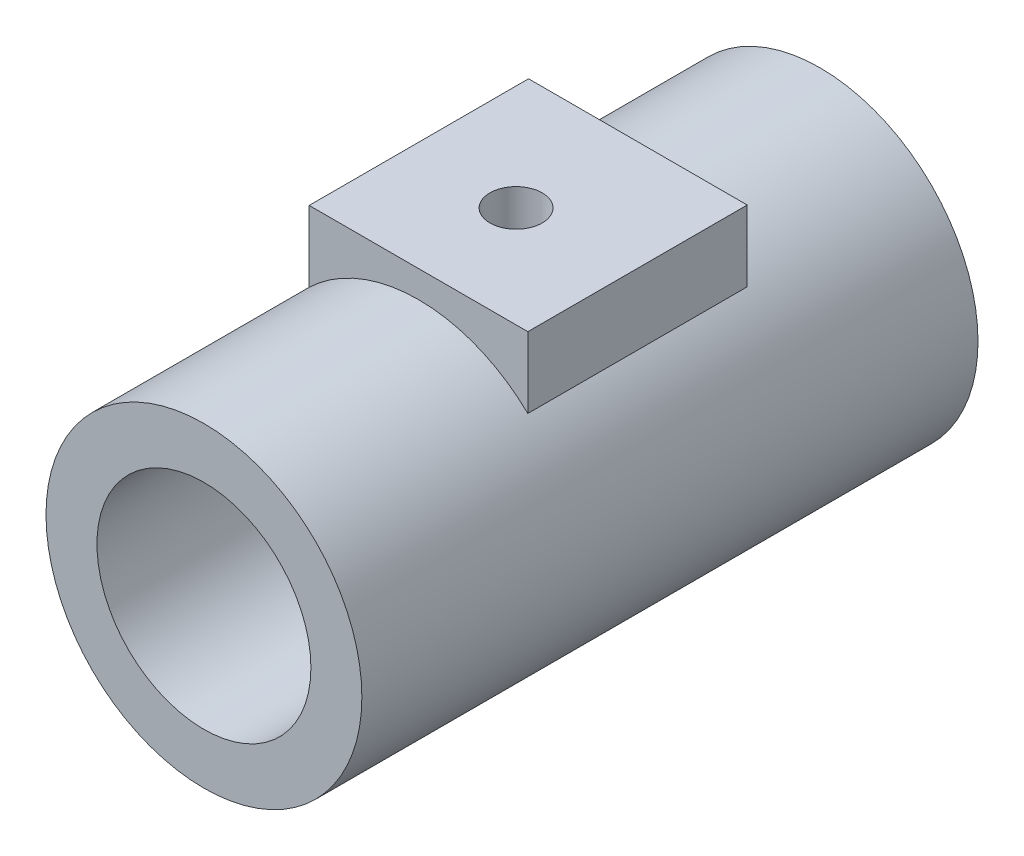
from build123d import *

# Parameters (mm, degrees)
SKETCH16_R               = 38.448520448
BOSS_EXTRUDE3_DEPTH      = 150
SKETCH17_R               = 26.04625397
CUT_EXTRUDE2_DEPTH       = 1
CUT_EXTRUDE2_DEPTH_BACK  = 151
SKETCH18_R               = 18.685585603
CUT_EXTRUDE3_DEPTH       = 39.448520448
CUT_EXTRUDE3_DEPTH_BACK  = 1
SKETCH19_W               = 53.228745634
SKETCH19_H               = 53.407658992
BOSS_EXTRUDE4_DEPTH      = 45
BOSS_EXTRUDE4_DEPTH_BACK = 1
SKETCH20_R               = 22.488274744
CUT_EXTRUDE4_DEPTH       = 46
CUT_EXTRUDE4_DEPTH_BACK  = 1
SKETCH21_W               = 53.228745634
SKETCH21_H               = 53.043515862
BOSS_EXTRUDE5_DEPTH      = 45
SKETCH22_R               = 6.364118175
CUT_EXTRUDE5_DEPTH       = 55
CUT_EXTRUDE5_DEPTH_BACK  = 1


with BuildPart() as part:
    # Sketch16 → Boss-Extrude3 (new body)
    with BuildSketch(Plane.XY):
        Circle(SKETCH16_R)
    extrude(amount=BOSS_EXTRUDE3_DEPTH)

    # Sketch17 → Cut-Extrude2 (cut, two sides)
    with BuildSketch(Plane.XY.offset(150)) as cut_extrude2_sk:
        Circle(SKETCH17_R)
    extrude(amount=CUT_EXTRUDE2_DEPTH, mode=Mode.SUBTRACT)
    extrude(cut_extrude2_sk.sketch, amount=-CUT_EXTRUDE2_DEPTH_BACK, mode=Mode.SUBTRACT)

    # Sketch18 → Cut-Extrude3 (cut, two sides)
    with BuildSketch(Plane(origin=(0, 0, 0), x_dir=(1, 0, 0), z_dir=(0, 1, 0))) as cut_extrude3_sk:
        with Locations((0, -71.055116097)):
            Circle(SKETCH18_R)
    extrude(amount=CUT_EXTRUDE3_DEPTH, mode=Mode.SUBTRACT)
    extrude(cut_extrude3_sk.sketch, amount=-CUT_EXTRUDE3_DEPTH_BACK, mode=Mode.SUBTRACT)

    # Sketch19 → Boss-Extrude4 (add, two sides)
    with BuildSketch(Plane(origin=(0, 0, 0), x_dir=(1, 0, 0), z_dir=(0, 1, 0))) as boss_extrude4_sk:
        with Locations((0, -71.055116097)):
            Rectangle(SKETCH19_W, SKETCH19_H)
    extrude(amount=BOSS_EXTRUDE4_DEPTH)
    extrude(boss_extrude4_sk.sketch, amount=-BOSS_EXTRUDE4_DEPTH_BACK)

    # Sketch20 → Cut-Extrude4 (cut, two sides)
    with BuildSketch(Plane(origin=(0, 0, 0), x_dir=(1, 0, 0), z_dir=(0, 1, 0))) as cut_extrude4_sk:
        with Locations((0, -71.055116097)):
            Circle(SKETCH20_R)
    extrude(amount=CUT_EXTRUDE4_DEPTH, mode=Mode.SUBTRACT)
    extrude(cut_extrude4_sk.sketch, amount=-CUT_EXTRUDE4_DEPTH_BACK, mode=Mode.SUBTRACT)

    # Sketch21 → Boss-Extrude5 (add)
    with BuildSketch(Plane(origin=(0, 0, 0), x_dir=(1, 0, 0), z_dir=(0, 1, 0))):
        with Locations((0, -71.237187662)):
            Rectangle(SKETCH21_W, SKETCH21_H)
    extrude(amount=BOSS_EXTRUDE5_DEPTH)

    # Sketch22 → Cut-Extrude5 (cut, two sides)
    with BuildSketch(Plane(origin=(0, 0, 0), x_dir=(1, 0, 0), z_dir=(0, 1, 0))) as cut_extrude5_sk:
        with Locations((-0.905733708, -73.105080143)):
            Circle(SKETCH22_R)
    extrude(amount=CUT_EXTRUDE5_DEPTH, mode=Mode.SUBTRACT)
    extrude(cut_extrude5_sk.sketch, amount=-CUT_EXTRUDE5_DEPTH_BACK, mode=Mode.SUBTRACT)


solid = part.part
